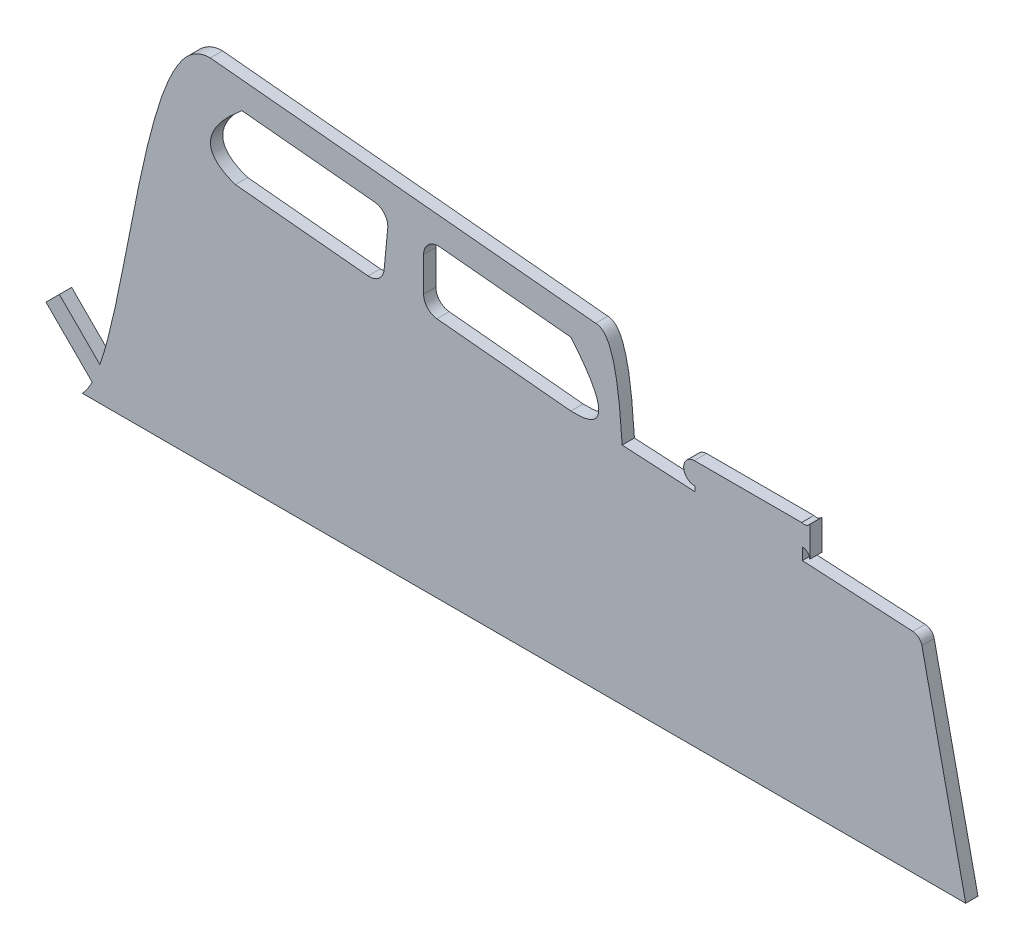
from build123d import *

# Parameters (mm, degrees)
BOSS_EXTRUDE1_DEPTH = 3.175
CUT_EXTRUDE1_DEPTH  = 3.175


with BuildPart() as part:
    # Sketch1 → Boss-Extrude1 (new body)
    with BuildSketch(Plane.XY):
        with BuildLine():
            add(Edge.make_bspline(
                [(2.579059818, 3.776412267), (1.767727302, 2.156821837), (0.911850586, 0.875503614), (0, 0)],
                knots=[0.923802309, 0.923802309, 0.923802309, 0.923802309, 1, 1, 1, 1], degree=3))
            Line((0, 0), (228.6, 0))
            Line((228.6, 0), (222.76882451, 26.801768915))
            Line((222.76882451, 26.801768915), (221.564922434, 32.335251021))
            Line((221.564922434, 32.335251021), (217.266059518, 52.094068206))
            ThreePointArc((217.266059518, 52.094068206), (216.431616334, 53.487306889), (214.923678652, 54.090244201))
            Line((214.923678652, 54.090244201), (186.335881614, 55.663335735))
            Line((186.335881614, 55.663335735), (186.335881614, 58.711335735))
            ThreePointArc((186.335881614, 58.711335735), (186.392581362, 58.712200587), (186.449281111, 58.711335735))
            ThreePointArc((186.449281111, 58.711335735), (187.700530121, 58.174263199), (188.250106948, 56.928455707))
            Line((188.250106948, 56.928455707), (188.250106948, 64.751418591))
            ThreePointArc((188.250106948, 64.751418591), (187.302878972, 64.075530467), (186.139401367, 64.095163563))
            Line((186.139401367, 64.095163563), (158.379745694, 64.095163563))
            ThreePointArc((158.379745694, 64.095163563), (155.621285283, 61.22392358), (158.492525265, 58.46546317))
            Line((158.492525265, 58.46546317), (158.492525265, 57.19546317))
            Line((158.492525265, 57.19546317), (139.704230031, 58.229320662))
            add(Edge.make_bspline(
                [(139.704230031, 58.229320662), (139.045260228, 67.775421627), (137.97702794, 82.099142771), (132.841802065, 82.099142771)],
                knots=[0, 0, 0, 0, 1, 1, 1, 1], degree=3))
            Line((132.841802065, 82.099142771), (33.135927245, 91.696329699))
            add(Edge.make_bspline(
                [(33.135927245, 91.696329699), (29.992946755, 91.696329699), (16.218901468, 82.07109656), (11.469233026, 28.631681198), (4.58927934, 8.68731164)],
                knots=[0, 0, 0, 0, 0.15232143, 0.857980154, 0.857980154, 0.857980154, 0.857980154], degree=3))
            Line((4.58927934, 8.68731164), (-5.906819212, 19.183410193))
            Line((-5.906819212, 19.183410193), (-9.36737866, 15.722850745))
            Line((-9.36737866, 15.722850745), (2.579059818, 3.776412267))
        make_face()
    extrude(amount=BOSS_EXTRUDE1_DEPTH)

    # Sketch2 → Cut-Extrude1 (cut)
    with BuildSketch(Plane.XY.offset(3.175)):
        with BuildLine():
            Line((41.317655172, 83.967201614), (75.625183332, 80.664931197))
            ThreePointArc((75.625183332, 80.664931197), (78.199946888, 79.296016613), (79.052610873, 76.507415058))
            Line((79.052610873, 76.507415058), (78.107945762, 66.693220334))
            ThreePointArc((78.107945762, 66.693220334), (76.739031178, 64.118456778), (73.950429623, 63.265792793))
            Line((73.950429623, 63.265792793), (39.642901463, 66.568063209))
            add(Edge.make_bspline(
                [(41.317655172, 83.967201614), (25.947965106, 71.264134292), (39.642901463, 66.568063209)],
                knots=[0, 0, 0, 1, 1, 1], degree=2))
        make_face()
        with BuildLine():
            Line((92.508115474, 79.039864911), (126.433071175, 75.774418999))
            add(Edge.make_bspline(
                [(126.433071175, 75.774418999), (140.857755692, 58.596738855), (126.433071175, 59.233433778)],
                knots=[0, 0, 0, 1, 1, 1], degree=2))
            Line((126.433071175, 59.233433778), (91.778026876, 62.569154354))
            ThreePointArc((91.778026876, 62.569154354), (89.322883346, 63.799861058), (88.333071175, 66.361626194))
            Line((88.333071175, 66.361626194), (88.333071175, 75.247393071))
            ThreePointArc((88.333071175, 75.247393071), (89.581306039, 78.0675809), (92.508115474, 79.039864911))
        make_face()
    extrude(amount=-CUT_EXTRUDE1_DEPTH, mode=Mode.SUBTRACT)


solid = part.part
